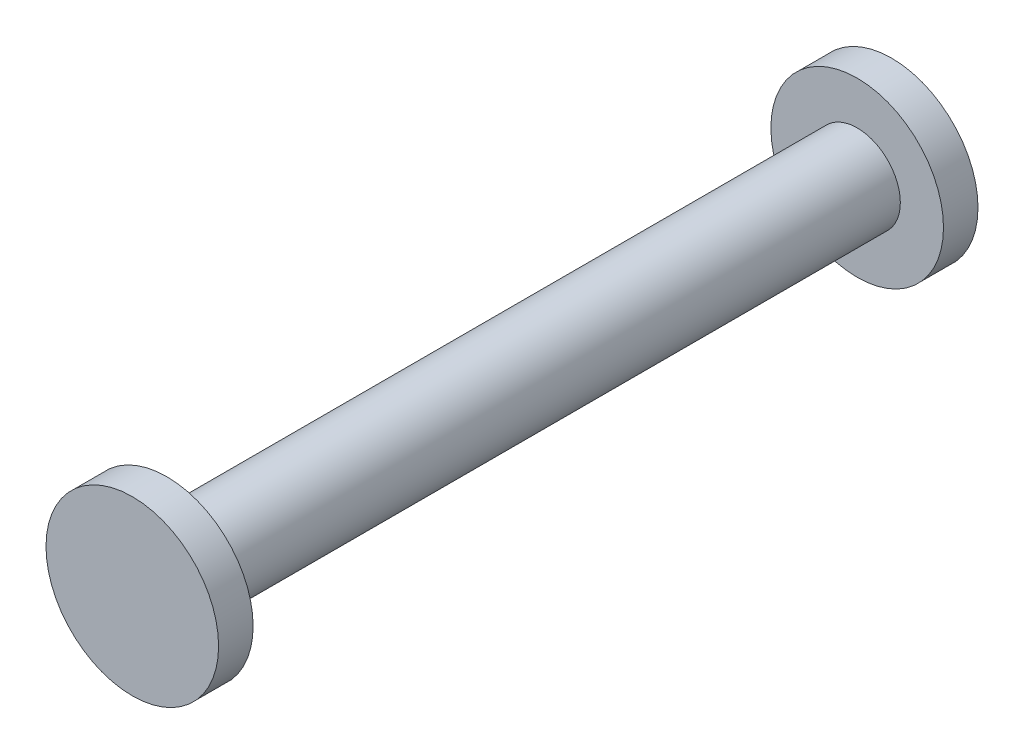
from build123d import *

# Parameters (mm, degrees)
SKETCH1_R           = 3.175
BOSS_EXTRUDE1_DEPTH = 50.8
SKETCH3_R           = 6.35
BOSS_EXTRUDE2_DEPTH = 2.54


with BuildPart() as part:
    # Sketch1 → Boss-Extrude1 (new body)
    with BuildSketch(Plane.XY):
        Circle(SKETCH1_R)
    extrude(amount=BOSS_EXTRUDE1_DEPTH)

    # Sketch3 → Boss-Extrude2 (add)
    with BuildSketch(Plane.XY.offset(50.8)):
        Circle(SKETCH3_R)
    boss_extrude2 = extrude(amount=BOSS_EXTRUDE2_DEPTH)

    # Mirror1: Boss-Extrude2 across plane
    add(boss_extrude2.mirror(Plane.XY.offset(25.4)))


solid = part.part
